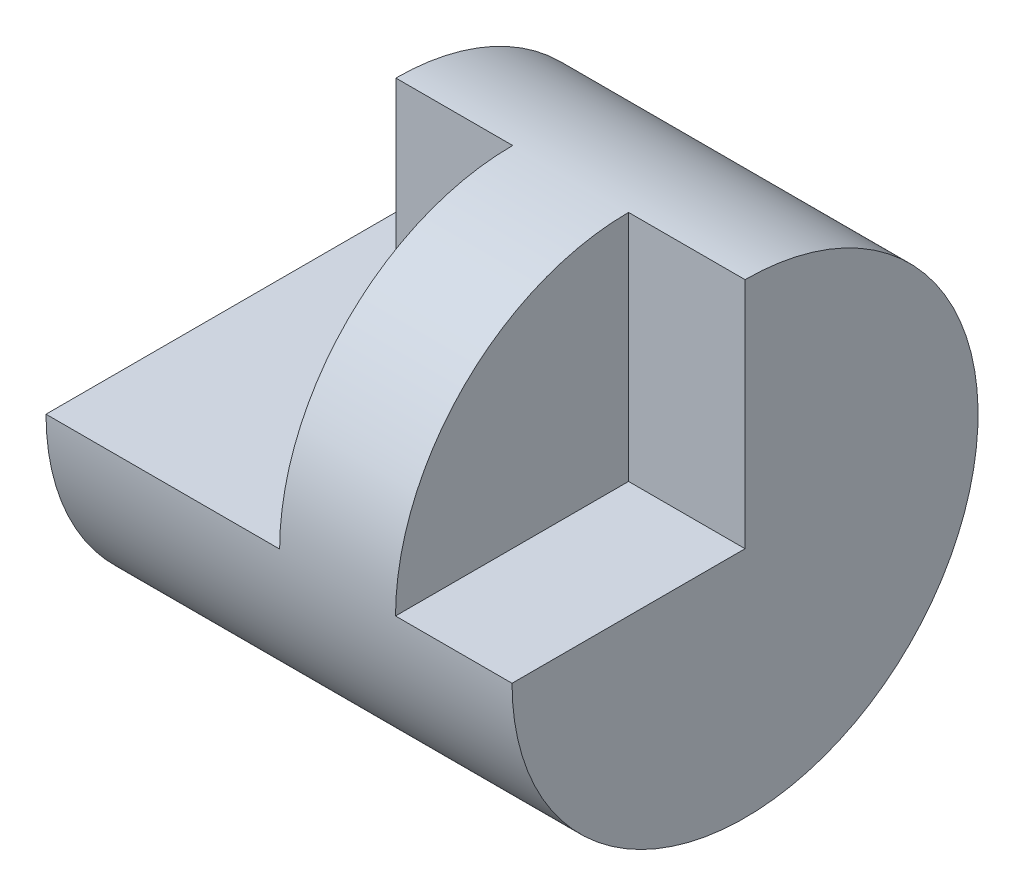
from build123d import *

# Parameters (mm, degrees)
SKETCH5_W          = 4
SKETCH5_H          = 2
SKETCH6_W          = 1
SKETCH6_H          = 2
CUT_EXTRUDE5_DEPTH = 11
SKETCH7_W          = 1.005381091
SKETCH7_H          = 2
CUT_EXTRUDE6_DEPTH = 3
SKETCH8_W          = 1.002690545
SKETCH8_H          = 2
CUT_EXTRUDE7_DEPTH = 10


with BuildPart() as part:
    # Sketch5 → Revolve-Thin2 (revolve)
    with BuildSketch(Plane.XY):
        with Locations((2, 1)):
            Rectangle(SKETCH5_W, SKETCH5_H)
    revolve(axis=Axis((0, 0, 0), (1, 0, 0)))

    # Sketch6 → Cut-Extrude5 (cut)
    with BuildSketch(Plane.XY):
        with Locations((3.5, 1)):
            Rectangle(SKETCH6_W, SKETCH6_H)
        with Locations((0.5, 1)):
            Rectangle(SKETCH6_W, SKETCH6_H)
    extrude(amount=CUT_EXTRUDE5_DEPTH, mode=Mode.SUBTRACT)

    # Sketch7 → Cut-Extrude6 (cut)
    with BuildSketch(Plane(origin=(0, 0, 0), x_dir=(1, 0, 0), z_dir=(0, 1, 0))):
        with Locations((1.502690546, -1)):
            Rectangle(SKETCH7_W, SKETCH7_H)
    extrude(amount=CUT_EXTRUDE6_DEPTH, mode=Mode.SUBTRACT)

    # Sketch8 → Cut-Extrude7 (cut)
    with BuildSketch(Plane.XY):
        with Locations((0.501345273, 1)):
            Rectangle(SKETCH8_W, SKETCH8_H)
    extrude(amount=-CUT_EXTRUDE7_DEPTH, mode=Mode.SUBTRACT)


solid = part.part
